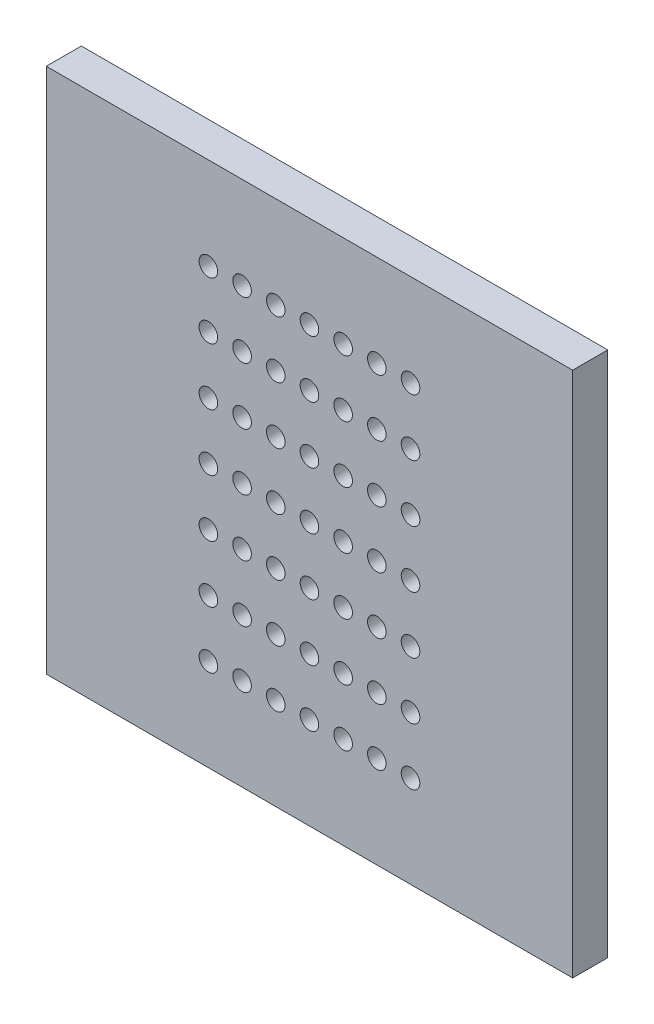
from build123d import *

# Parameters (mm, degrees)
ESQUISSE1_W            = 30
ESQUISSE1_H            = 30
BASE_PLATE_DEPTH       = 2
SKETCH_PERFORATIONS_R  = 0.53
CUT_PERFORATIONS_DEPTH = 10


with BuildPart() as part:
    # Esquisse1 → Base_Plate (new body)
    with BuildSketch(Plane.XY):
        Rectangle(ESQUISSE1_W, ESQUISSE1_H)
    extrude(amount=BASE_PLATE_DEPTH)

    # Sketch_Perforations → Cut_Perforations (cut)
    with BuildSketch(Plane.XY.offset(2)):
        with Locations((-5.76, -9.75)):
            Circle(SKETCH_PERFORATIONS_R)
        with Locations((-5.76, -6.5)):
            Circle(SKETCH_PERFORATIONS_R)
        with Locations((-5.76, -3.25)):
            Circle(SKETCH_PERFORATIONS_R)
        with Locations((-5.76, 0)):
            Circle(SKETCH_PERFORATIONS_R)
        with Locations((-5.76, 3.25)):
            Circle(SKETCH_PERFORATIONS_R)
        with Locations((-5.76, 6.5)):
            Circle(SKETCH_PERFORATIONS_R)
        with Locations((-5.76, 9.75)):
            Circle(SKETCH_PERFORATIONS_R)
        with Locations((-3.84, -9.75)):
            Circle(SKETCH_PERFORATIONS_R)
        with Locations((-3.84, -6.5)):
            Circle(SKETCH_PERFORATIONS_R)
        with Locations((-3.84, -3.25)):
            Circle(SKETCH_PERFORATIONS_R)
        with Locations((-3.84, 0)):
            Circle(SKETCH_PERFORATIONS_R)
        with Locations((-3.84, 3.25)):
            Circle(SKETCH_PERFORATIONS_R)
        with Locations((-3.84, 6.5)):
            Circle(SKETCH_PERFORATIONS_R)
        with Locations((-3.84, 9.75)):
            Circle(SKETCH_PERFORATIONS_R)
        with Locations((-1.92, -9.75)):
            Circle(SKETCH_PERFORATIONS_R)
        with Locations((-1.92, -6.5)):
            Circle(SKETCH_PERFORATIONS_R)
        with Locations((-1.92, -3.25)):
            Circle(SKETCH_PERFORATIONS_R)
        with Locations((-1.92, 0)):
            Circle(SKETCH_PERFORATIONS_R)
        with Locations((-1.92, 3.25)):
            Circle(SKETCH_PERFORATIONS_R)
        with Locations((-1.92, 6.5)):
            Circle(SKETCH_PERFORATIONS_R)
        with Locations((-1.92, 9.75)):
            Circle(SKETCH_PERFORATIONS_R)
        with Locations((0, -9.75)):
            Circle(SKETCH_PERFORATIONS_R)
        with Locations((0, -6.5)):
            Circle(SKETCH_PERFORATIONS_R)
        with Locations((0, -3.25)):
            Circle(SKETCH_PERFORATIONS_R)
        Circle(SKETCH_PERFORATIONS_R)
        with Locations((0, 3.25)):
            Circle(SKETCH_PERFORATIONS_R)
        with Locations((0, 6.5)):
            Circle(SKETCH_PERFORATIONS_R)
        with Locations((0, 9.75)):
            Circle(SKETCH_PERFORATIONS_R)
        with Locations((1.92, -9.75)):
            Circle(SKETCH_PERFORATIONS_R)
        with Locations((1.92, -6.5)):
            Circle(SKETCH_PERFORATIONS_R)
        with Locations((1.92, -3.25)):
            Circle(SKETCH_PERFORATIONS_R)
        with Locations((1.92, 0)):
            Circle(SKETCH_PERFORATIONS_R)
        with Locations((1.92, 3.25)):
            Circle(SKETCH_PERFORATIONS_R)
        with Locations((1.92, 6.5)):
            Circle(SKETCH_PERFORATIONS_R)
        with Locations((1.92, 9.75)):
            Circle(SKETCH_PERFORATIONS_R)
        with Locations((3.84, -9.75)):
            Circle(SKETCH_PERFORATIONS_R)
        with Locations((3.84, -6.5)):
            Circle(SKETCH_PERFORATIONS_R)
        with Locations((3.84, -3.25)):
            Circle(SKETCH_PERFORATIONS_R)
        with Locations((3.84, 0)):
            Circle(SKETCH_PERFORATIONS_R)
        with Locations((3.84, 3.25)):
            Circle(SKETCH_PERFORATIONS_R)
        with Locations((3.84, 6.5)):
            Circle(SKETCH_PERFORATIONS_R)
        with Locations((3.84, 9.75)):
            Circle(SKETCH_PERFORATIONS_R)
        with Locations((5.76, -9.75)):
            Circle(SKETCH_PERFORATIONS_R)
        with Locations((5.76, -6.5)):
            Circle(SKETCH_PERFORATIONS_R)
        with Locations((5.76, -3.25)):
            Circle(SKETCH_PERFORATIONS_R)
        with Locations((5.76, 0)):
            Circle(SKETCH_PERFORATIONS_R)
        with Locations((5.76, 3.25)):
            Circle(SKETCH_PERFORATIONS_R)
        with Locations((5.76, 6.5)):
            Circle(SKETCH_PERFORATIONS_R)
        with Locations((5.76, 9.75)):
            Circle(SKETCH_PERFORATIONS_R)
    extrude(amount=-CUT_PERFORATIONS_DEPTH, mode=Mode.SUBTRACT)


solid = part.part
